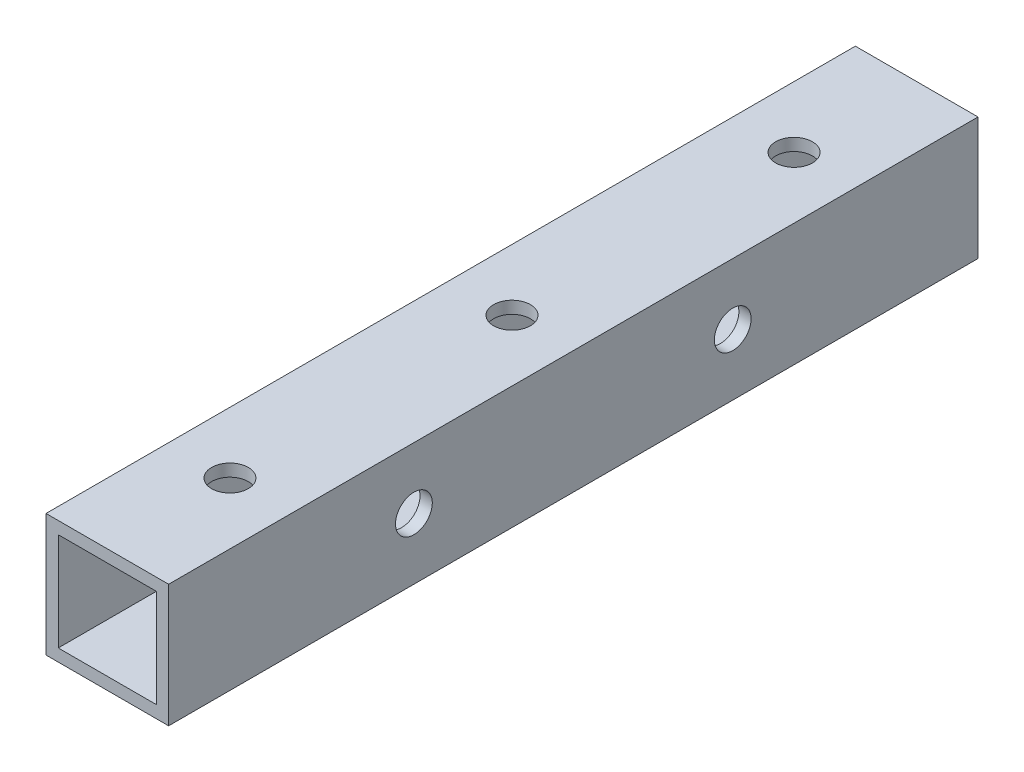
from build123d import *

# Parameters (mm, degrees)
SKETCH_1_W          = 10
SKETCH_1_H          = 10
SKETCH_1_W_2        = 8
SKETCH_1_H_2        = 8
EXTRUDE_1_DEPTH     = 66
SKETCH_2_R          = 1.5
CUT_EXTRUDE_1_DEPTH = 11
SKETCH_3_R          = 1.5
CUT_EXTRUDE_2_DEPTH = 11


with BuildPart() as part:
    # 草图1 → 拉伸-薄壁1 (new body)
    with BuildSketch(Plane.XY):
        with Locations((-63.129584871, 113.346996024)):
            Rectangle(SKETCH_1_W, SKETCH_1_H)
        with Locations((-63.129584871, 113.346996024)):
            Rectangle(SKETCH_1_W_2, SKETCH_1_H_2, mode=Mode.SUBTRACT)
    extrude(amount=EXTRUDE_1_DEPTH)

    # 草图2 → 切除-拉伸1 (cut, through all)
    with BuildSketch(Plane(origin=(-58.129584871, 0, 0), x_dir=(0, 0, -1), z_dir=(1, 0, 0))):
        with Locations((-20, 113.346996024)):
            Circle(SKETCH_2_R)
        with Locations((-46, 113.346996024)):
            Circle(SKETCH_2_R)
    extrude(amount=-CUT_EXTRUDE_1_DEPTH, mode=Mode.SUBTRACT)

    # 草图3 → 切除-拉伸2 (cut, through all)
    with BuildSketch(Plane.XZ.offset(-108.346996024)):
        with Locations((-63.129584871, 10)):
            Circle(SKETCH_3_R)
        with Locations((-63.129584871, 56)):
            Circle(SKETCH_3_R)
        with Locations((-63.129584871, 33)):
            Circle(SKETCH_3_R)
    extrude(amount=-CUT_EXTRUDE_2_DEPTH, mode=Mode.SUBTRACT)


solid = part.part
